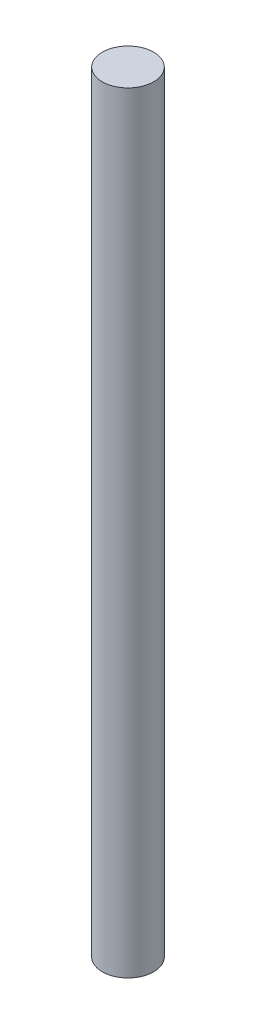
from build123d import *

# Parameters (mm, degrees)
SKETCH_1_R      = 2.5
EXTRUDE_1_DEPTH = 75


with BuildPart() as part:
    # 草图1 → 凸台-拉伸1 (new body)
    with BuildSketch(Plane(origin=(0, 0, 0), x_dir=(1, 0, 0), z_dir=(0, 1, 0))):
        Circle(SKETCH_1_R)
    extrude(amount=EXTRUDE_1_DEPTH)


solid = part.part
